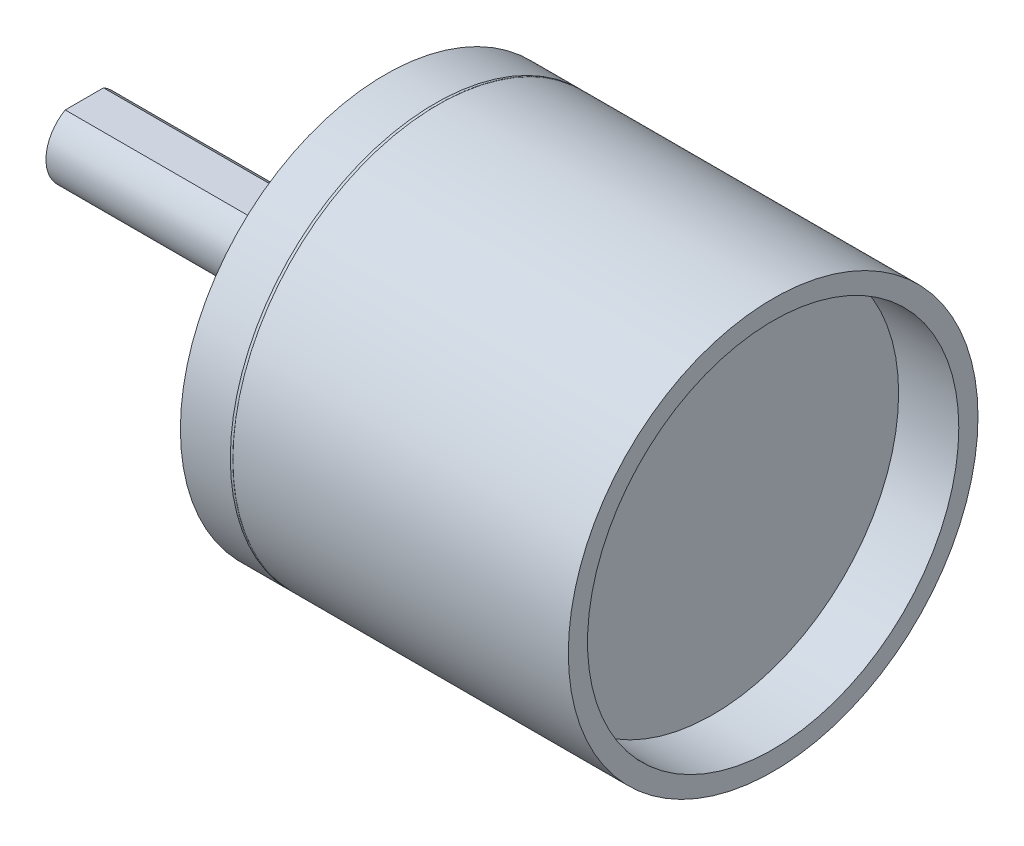
from build123d import *

# Parameters (mm, degrees)
SKETCH2_R                        = 3
BOSS_EXTRUDE1_DEPTH              = 1
SKETCH3_R                        = 2.5
BOSS_EXTRUDE2_DEPTH              = 1.6
SKETCH4_R                        = 1.5
BOSS_EXTRUDE3_DEPTH              = 9.15
CUT_EXTRUDE1_DEPTH               = 7.8
DRAFT1_ANGLE                     = 44.5
F_14_5_14_5_DIAMETER_HOLE1_D     = 14.5
F_14_5_14_5_DIAMETER_HOLE1_DEPTH = 2.35
F_1_6_1_6_DIAMETER_HOLE1_D       = 1.6
F_1_6_1_6_DIAMETER_HOLE1_DEPTH   = 3
F_1_6_1_6_DIAMETER_HOLE1_TIP     = 0.480688495


with BuildPart() as part:
    # Sketch1 → Revolve1 (revolve)
    with BuildSketch(Plane.XY):
        with BuildLine():
            Line((0, 8), (0, 0))
            Line((0, 0), (15.15, 0))
            Line((15.15, 0), (15.15, 8))
            Line((15.15, 8), (2.05, 8))
            ThreePointArc((2.05, 8), (2, 7.98660254), (1.95, 8))
            Line((1.95, 8), (0, 8))
        make_face()
    revolve(axis=Axis((0, 0, 0), (1, 0, 0)))

    # Sketch2 → Boss-Extrude1 (add)
    with BuildSketch(Plane.ZY):
        Circle(SKETCH2_R)
    extrude(amount=BOSS_EXTRUDE1_DEPTH)

    # Sketch3 → Boss-Extrude2 (add)
    with BuildSketch(Plane.ZY.offset(1)):
        Circle(SKETCH3_R)
    extrude(amount=BOSS_EXTRUDE2_DEPTH)

    # Sketch4 → Boss-Extrude3 (add)
    with BuildSketch(Plane.ZY.offset(2.6)):
        Circle(SKETCH4_R)
    extrude(amount=BOSS_EXTRUDE3_DEPTH)

    # Sketch5 → Cut-Extrude1 (cut)
    with BuildSketch(Plane.ZY.offset(11.75)):
        with BuildLine():
            Line((-0.748331477, 1.3), (0.748331477, 1.3))
            ThreePointArc((0.748331477, 1.3), (0, 1.5), (-0.748331477, 1.3))
        make_face()
    extrude(amount=-CUT_EXTRUDE1_DEPTH, mode=Mode.SUBTRACT)

    # Draft1
    draft1_faces = [part.faces().sort_by_distance(p)[0] for p in [
        (-3.95, 1.380475515, 0),
    ]]
    draft(draft1_faces, Plane(origin=(-3.95, 1.3, -0.748331477), x_dir=(0, 0, 1), z_dir=(0, 1, 0)), DRAFT1_ANGLE)

    # Ø14.5 (14.5) Diameter Hole1
    with Locations(Plane(origin=(15.15, 0, 0), x_dir=(0, 0, -1), z_dir=(1, 0, 0))):
        with Locations((0, 0)):
            Hole(F_14_5_14_5_DIAMETER_HOLE1_D / 2, depth=F_14_5_14_5_DIAMETER_HOLE1_DEPTH)

    # Ø1.6 (1.6) Diameter Hole1
    with Locations(Plane.ZY):
        with Locations((8.727e-06, 5), (4.330131382, 2.499992442), (4.330122656, -2.500007557), (-8.727e-06, -5), (-4.330131382, -2.499992442), (-4.330122656, 2.500007557)):
            Hole(F_1_6_1_6_DIAMETER_HOLE1_D / 2, depth=F_1_6_1_6_DIAMETER_HOLE1_DEPTH)
            with Locations((0, 0, -(F_1_6_1_6_DIAMETER_HOLE1_DEPTH + F_1_6_1_6_DIAMETER_HOLE1_TIP / 2))):  # 118° drill point
                Cone(0, F_1_6_1_6_DIAMETER_HOLE1_D / 2, F_1_6_1_6_DIAMETER_HOLE1_TIP, mode=Mode.SUBTRACT)


solid = part.part
